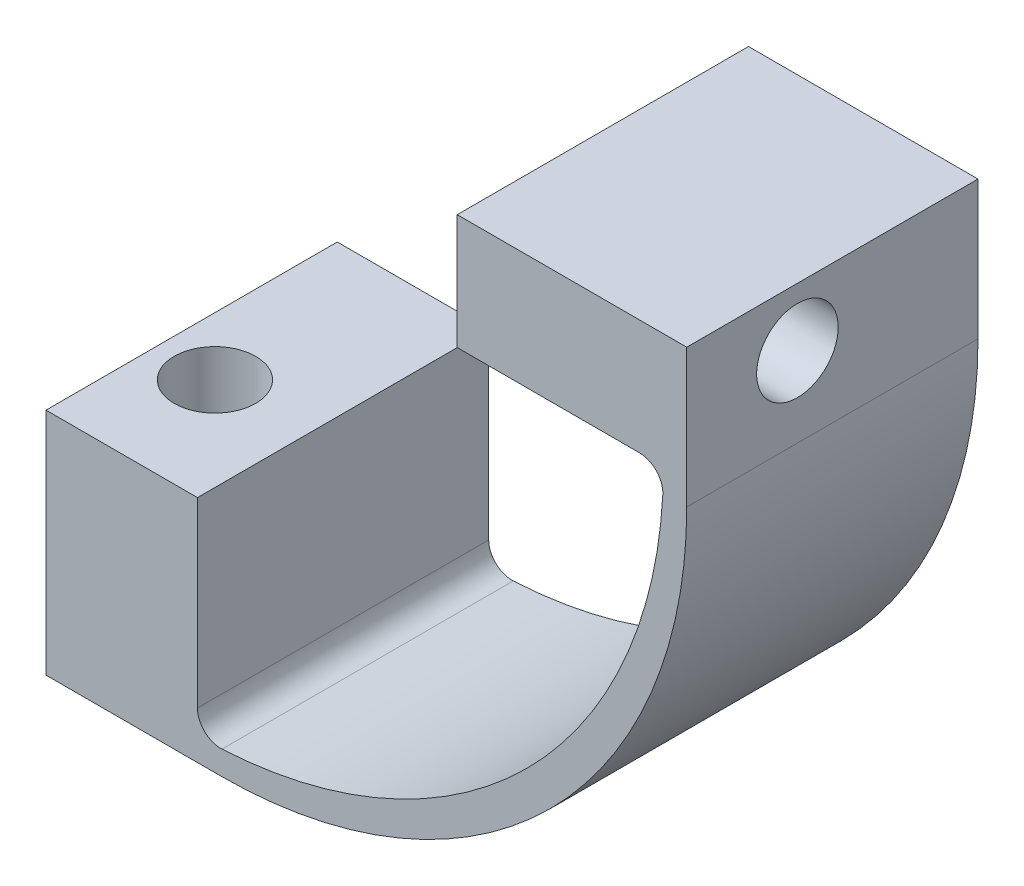
from build123d import *

# Parameters (mm, degrees)
SKETCH1_W           = 55
SKETCH1_H           = 25
SKETCH1_R           = 3.5
BOSS_EXTRUDE1_DEPTH = 2
SKETCH2_W           = 25
SKETCH2_H           = 51.88
SKETCH2_R           = 3.5
BOSS_EXTRUDE2_DEPTH = 2
FILLET2_R           = 40
SKETCH5_W           = 13
SKETCH5_H           = 25
SKETCH5_R           = 3.5
BOSS_EXTRUDE5_DEPTH = 17.7
SKETCH6_W           = 25
SKETCH6_H           = 9.88
SKETCH6_R           = 3.5
BOSS_EXTRUDE6_DEPTH = 17.7
FILLET3_R           = 2
FILLET4_R           = 2


with BuildPart() as part:
    # Sketch1 → Boss-Extrude1 (new body)
    with BuildSketch(Plane(origin=(0, 0, 0), x_dir=(1, 0, 0), z_dir=(0, 1, 0))):
        with Locations((22.5, 3)):
            Rectangle(SKETCH1_W, SKETCH1_H)
        with Locations(Location((0, 0, 0), (0, 0, 270))):
            Circle(SKETCH1_R, mode=Mode.SUBTRACT)
    extrude(amount=BOSS_EXTRUDE1_DEPTH)

    # Sketch2 → Boss-Extrude2 (add)
    with BuildSketch(Plane(origin=(50, 0, 0), x_dir=(0, 0, -1), z_dir=(1, 0, 0))):
        with Locations((3, 25.94)):
            Rectangle(SKETCH2_W, SKETCH2_H)
        with Locations((0, 46.88)):
            Circle(SKETCH2_R, mode=Mode.SUBTRACT)
    extrude(amount=-BOSS_EXTRUDE2_DEPTH)

    # Fillet2
    fillet2_edges = [part.edges().sort_by_distance(p)[0] for p in [
        (48, 2, -3),
        (50, 0, -3),
    ]]
    fillet(fillet2_edges, radius=FILLET2_R)

    # Sketch5 → Boss-Extrude5 (add)
    with BuildSketch(Plane(origin=(0, 2, 0), x_dir=(1, 0, 0), z_dir=(0, 1, 0))):
        with Locations((1.5, 3)):
            Rectangle(SKETCH5_W, SKETCH5_H)
        with Locations(Location((0, 0, 0), (0, 0, 270))):
            Circle(SKETCH5_R, mode=Mode.SUBTRACT)
    extrude(amount=BOSS_EXTRUDE5_DEPTH)

    # Sketch6 → Boss-Extrude6 (add)
    with BuildSketch(Plane.ZY.offset(-48)):
        with Locations((-3, 46.94)):
            Rectangle(SKETCH6_W, SKETCH6_H)
        with Locations(Location((0, 46.88, 0), (0, 0, 180))):
            Circle(SKETCH6_R, mode=Mode.SUBTRACT)
    extrude(amount=BOSS_EXTRUDE6_DEPTH)

    # Fillet3
    fillet3_edges = [part.edges().sort_by_distance(p)[0] for p in [
        (48, 42, -3),
    ]]
    fillet(fillet3_edges, radius=FILLET3_R)

    # Fillet4
    fillet4_edges = [part.edges().sort_by_distance(p)[0] for p in [
        (8, 2, -3),
    ]]
    fillet(fillet4_edges, radius=FILLET4_R)


solid = part.part
